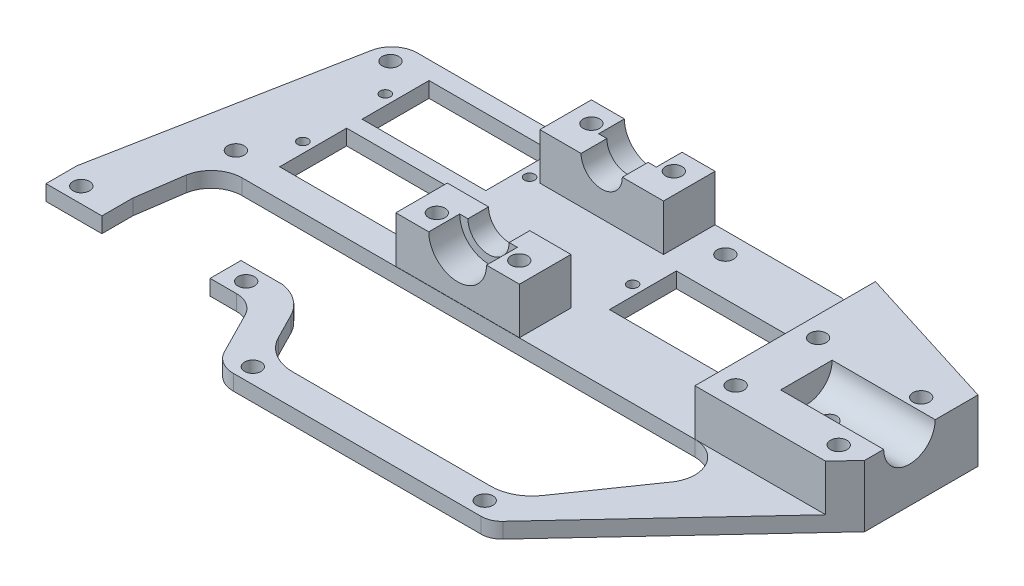
from build123d import *

# Parameters (mm, degrees)
SKETCH_1_R          = 1.6
SKETCH_1_R_2        = 1
SKETCH_1_W          = 24
SKETCH_1_H          = 13
EXTRUDE_1_DEPTH     = 3
SKETCH_2_R          = 1.6
SKETCH_2_W          = 24
SKETCH_2_H          = 10
EXTRUDE_2_DEPTH     = 9
SKETCH_3_R          = 5
CUT_EXTRUDE_1_DEPTH = 20
SKETCH_4_R          = 4
CUT_EXTRUDE_2_DEPTH = 72.704206567
SKETCH_6_R          = 5.6
CUT_EXTRUDE_3_DEPTH = 5
SKETCH_7_R          = 5.6
CUT_EXTRUDE_4_DEPTH = 6
FILLET_5_R          = 5
FILLET_6_R          = 5
SKETCH_8_W          = 21
SKETCH_8_H          = 6
CUT_EXTRUDE_5_DEPTH = 4.0000001


with BuildPart() as part:
    # Эскиз1 → Бобышка-Вытянуть1 (new body)
    with BuildSketch(Plane(origin=(0, 0, 0), x_dir=(1, 0, 0), z_dir=(0, 1, 0))):
        with BuildLine():
            Line((-59.846473334, -34), (-49.887758312, 18))
            Line((-49.887758312, 18), (36.612736258, 18))
            Line((36.612736258, 18), (75.112241688, 5.920216985))
            Line((75.112241688, 5.920216985), (75.112241688, -16.079783015))
            Line((75.112241688, -16.079783015), (41.245672077, -52.430849732))
            ThreePointArc((41.245672077, -52.430849732), (39.914841322, -53.372078747), (38.318998701, -53.704206567))
            Line((38.318998701, -53.704206567), (-9.799827382, -53.704206567))
            ThreePointArc((-9.799827382, -53.704206567), (-12.412320205, -52.967407389), (-14.254860003, -50.974159066))
            Line((-14.254860003, -50.974159066), (-19.846473334, -40))
            Line((-19.846473334, -40), (-59.846473334, -40))
            Line((-59.846473334, -40), (-59.846473334, -34))
        make_face()
        with Locations((-8, 14)):
            Circle(SKETCH_1_R, mode=Mode.SUBTRACT)
        with Locations((8, 14)):
            Circle(SKETCH_1_R, mode=Mode.SUBTRACT)
        with Locations((-8, -16)):
            Circle(SKETCH_1_R, mode=Mode.SUBTRACT)
        with Locations((8, -16)):
            Circle(SKETCH_1_R, mode=Mode.SUBTRACT)
        with Locations((-47, 14)):
            Circle(SKETCH_1_R, mode=Mode.SUBTRACT)
        with Locations((70, 0)):
            Circle(SKETCH_1_R, mode=Mode.SUBTRACT)
        with Locations((50, 0)):
            Circle(SKETCH_1_R, mode=Mode.SUBTRACT)
        with Locations((18, 14)):
            Circle(SKETCH_1_R, mode=Mode.SUBTRACT)
        with Locations((-47, -16)):
            Circle(SKETCH_1_R, mode=Mode.SUBTRACT)
        with Locations((-56, -37)):
            Circle(SKETCH_1_R, mode=Mode.SUBTRACT)
        with Locations((-24, -37)):
            Circle(SKETCH_1_R, mode=Mode.SUBTRACT)
        with Locations((50, -16)):
            Circle(SKETCH_1_R, mode=Mode.SUBTRACT)
        with Locations((70, -16)):
            Circle(SKETCH_1_R, mode=Mode.SUBTRACT)
        with Locations((-9, -50.704206567)):
            Circle(SKETCH_1_R, mode=Mode.SUBTRACT)
        with Locations((36, -50.704206567)):
            Circle(SKETCH_1_R, mode=Mode.SUBTRACT)
        with Locations((60, -8)):
            Circle(SKETCH_1_R, mode=Mode.SUBTRACT)
        with Locations((-42, -8)):
            Circle(SKETCH_1_R_2, mode=Mode.SUBTRACT)
        with Locations((-14, -8)):
            Circle(SKETCH_1_R_2, mode=Mode.SUBTRACT)
        with Locations((-42, 8)):
            Circle(SKETCH_1_R_2, mode=Mode.SUBTRACT)
        with Locations((-14, 8)):
            Circle(SKETCH_1_R_2, mode=Mode.SUBTRACT)
        with Locations((14, 0)):
            Circle(SKETCH_1_R_2, mode=Mode.SUBTRACT)
        with Locations((42, 0)):
            Circle(SKETCH_1_R_2, mode=Mode.SUBTRACT)
        with Locations((28, 0)):
            Rectangle(SKETCH_1_W, SKETCH_1_H, mode=Mode.SUBTRACT)
        with Locations((-28, 8)):
            Rectangle(SKETCH_1_W, SKETCH_1_H, mode=Mode.SUBTRACT)
        with Locations((-28, -8)):
            Rectangle(SKETCH_1_W, SKETCH_1_H, mode=Mode.SUBTRACT)
        with BuildLine():
            Line((-47.677053254, -24.900709984), (-49.000145857, -34))
            Line((-49.000145857, -34), (-22.297676486, -34))
            Line((-22.297676486, -34), (-19.846473334, -34))
            ThreePointArc((-19.846473334, -34), (-16.425778662, -35.467187694), (-13.988679802, -38.280431537))
            Line((-13.988679802, -38.280431537), (-11.413907263, -43.333707171))
            ThreePointArc((-11.413907263, -43.333707171), (-8.465843587, -46.522904488), (-4.28585507, -47.701783173))
            Line((-4.28585507, -47.701783173), (34.165827616, -47.701783173))
            ThreePointArc((34.165827616, -47.701783173), (37.877016972, -46.788889321), (40.741225842, -44.258551563))
            Line((40.741225842, -44.258551563), (51.02606102, -29.417576293))
            ThreePointArc((51.02606102, -29.417576293), (51.409841961, -23.216607983), (46.09451235, -20))
            Line((46.09451235, -20), (-41.778616049, -20))
            ThreePointArc((-41.778616049, -20), (-45.612951708, -21.385038456), (-47.677053254, -24.900709984))
        make_face(mode=Mode.SUBTRACT)
    extrude(amount=EXTRUDE_1_DEPTH)

    # Эскиз2 → Бобышка-Вытянуть2 (add)
    with BuildSketch(Plane(origin=(0, 3, 0), x_dir=(1, 0, 0), z_dir=(0, 1, 0))):
        Polygon((46.101706289, 15.022696844), (46.09451235, -20), (71.459960933, -20), (75.112241688, -16.079783015), (75.112241688, 5.920216985), align=None)
        with Locations((50, 0)):
            Circle(SKETCH_2_R, mode=Mode.SUBTRACT)
        with Locations((70, 0)):
            Circle(SKETCH_2_R, mode=Mode.SUBTRACT)
        with Locations((70, -16)):
            Circle(SKETCH_2_R, mode=Mode.SUBTRACT)
        with Locations((50, -16)):
            Circle(SKETCH_2_R, mode=Mode.SUBTRACT)
        with Locations((60, -8)):
            Circle(SKETCH_2_R, mode=Mode.SUBTRACT)
        with Locations((0, 13)):
            Rectangle(SKETCH_2_W, SKETCH_2_H)
        with Locations((-8, 14)):
            Circle(SKETCH_2_R, mode=Mode.SUBTRACT)
        with Locations((8, 14)):
            Circle(SKETCH_2_R, mode=Mode.SUBTRACT)
        with Locations((0, -14.961092538)):
            Rectangle(SKETCH_2_W, SKETCH_2_H)
        with Locations((-8, -16)):
            Circle(SKETCH_2_R, mode=Mode.SUBTRACT)
        with Locations((8, -16)):
            Circle(SKETCH_2_R, mode=Mode.SUBTRACT)
    extrude(amount=EXTRUDE_2_DEPTH)

    # Эскиз3 → Вырез-Вытянуть1 (cut)
    with BuildSketch(Plane(origin=(75.112241688, 0, 0), x_dir=(0, 0, -1), z_dir=(1, 0, 0))):
        with Locations((-7.384625177, 12)):
            Circle(SKETCH_3_R)
    extrude(amount=-CUT_EXTRUDE_1_DEPTH, mode=Mode.SUBTRACT)

    # Эскиз4 → Вырез-Вытянуть2 (cut, through all)
    with BuildSketch(Plane(origin=(0, 0, -18), x_dir=(-1, 0, 0), z_dir=(0, 0, -1))):
        with Locations((0, 12)):
            Circle(SKETCH_4_R)
    extrude(amount=-CUT_EXTRUDE_2_DEPTH, mode=Mode.SUBTRACT)

    # Эскиз6 → Вырез-Вытянуть3 (cut)
    with BuildSketch(Plane(origin=(0, 0, -18), x_dir=(-1, 0, 0), z_dir=(0, 0, -1))):
        with Locations((0, 12)):
            Circle(SKETCH_6_R)
    extrude(amount=-CUT_EXTRUDE_3_DEPTH, mode=Mode.SUBTRACT)

    # Эскиз7 → Вырез-Вытянуть4 (cut)
    with BuildSketch(Plane.XY.offset(19.961092538)):
        with Locations((0, 12)):
            Circle(SKETCH_7_R)
    extrude(amount=-CUT_EXTRUDE_4_DEPTH, mode=Mode.SUBTRACT)

    # Скругление5
    fillet_5_edges = [part.edges().sort_by_distance(p)[0] for p in [
        (-49.887758312, 1.5, -18),
    ]]
    fillet(fillet_5_edges, radius=FILLET_5_R)

    # Скругление6
    fillet_6_edges = [part.edges().sort_by_distance(p)[0] for p in [
        (-19.846473334, 1.5, 40),
    ]]
    fillet(fillet_6_edges, radius=FILLET_6_R)

    # Эскиз8 → Вырез-Вытянуть5 (cut, through all)
    with BuildSketch(Plane(origin=(0, 3, 0), x_dir=(1, 0, 0), z_dir=(0, 1, 0))):
        with Locations((-38.500145857, -37)):
            Rectangle(SKETCH_8_W, SKETCH_8_H)
    extrude(amount=-CUT_EXTRUDE_5_DEPTH, mode=Mode.SUBTRACT)


solid = part.part
